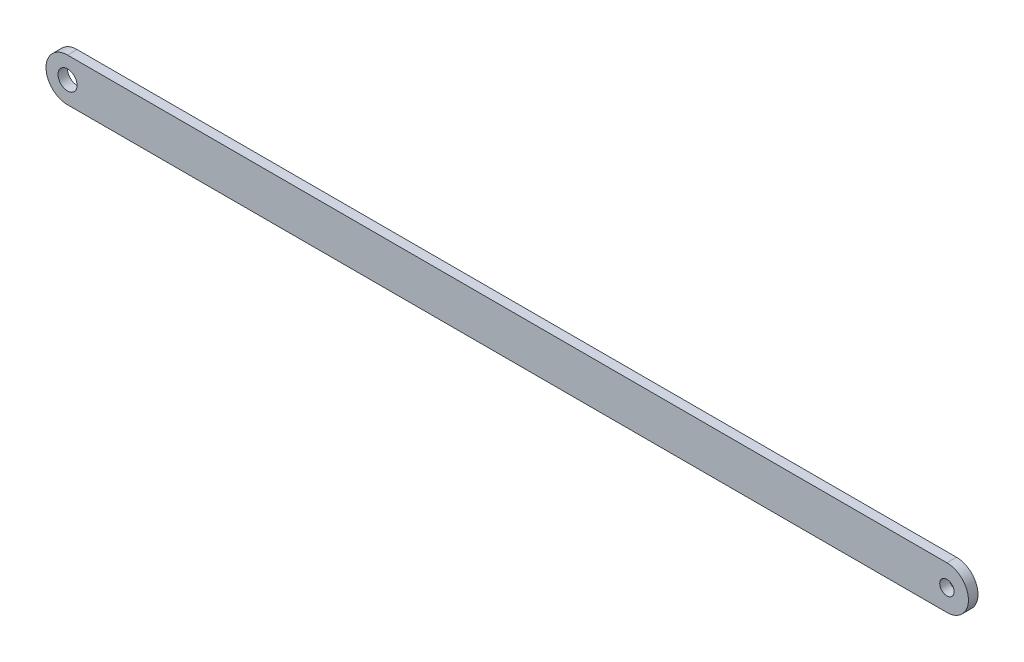
from build123d import *

# Parameters (mm, degrees)
SKETCH1_R           = 4
SKETCH1_R_2         = 3
BOSS_EXTRUDE1_DEPTH = 4


with BuildPart() as part:
    # Sketch1 → Boss-Extrude1 (new body)
    with BuildSketch(Plane.XY):
        with BuildLine():
            Line((-16.294818526, 9), (351.235181474, 9))
            ThreePointArc((351.235181474, 9), (360.235181474, 0), (351.235181474, -9))
            Line((351.235181474, -9), (-16.294818526, -9))
            ThreePointArc((-16.294818526, -9), (-25.294818526, 0), (-16.294818526, 9))
        make_face()
        with Locations((-16.294818526, 0)):
            Circle(SKETCH1_R, mode=Mode.SUBTRACT)
        with Locations((351.235181474, 0)):
            Circle(SKETCH1_R_2, mode=Mode.SUBTRACT)
    extrude(amount=BOSS_EXTRUDE1_DEPTH)


solid = part.part
